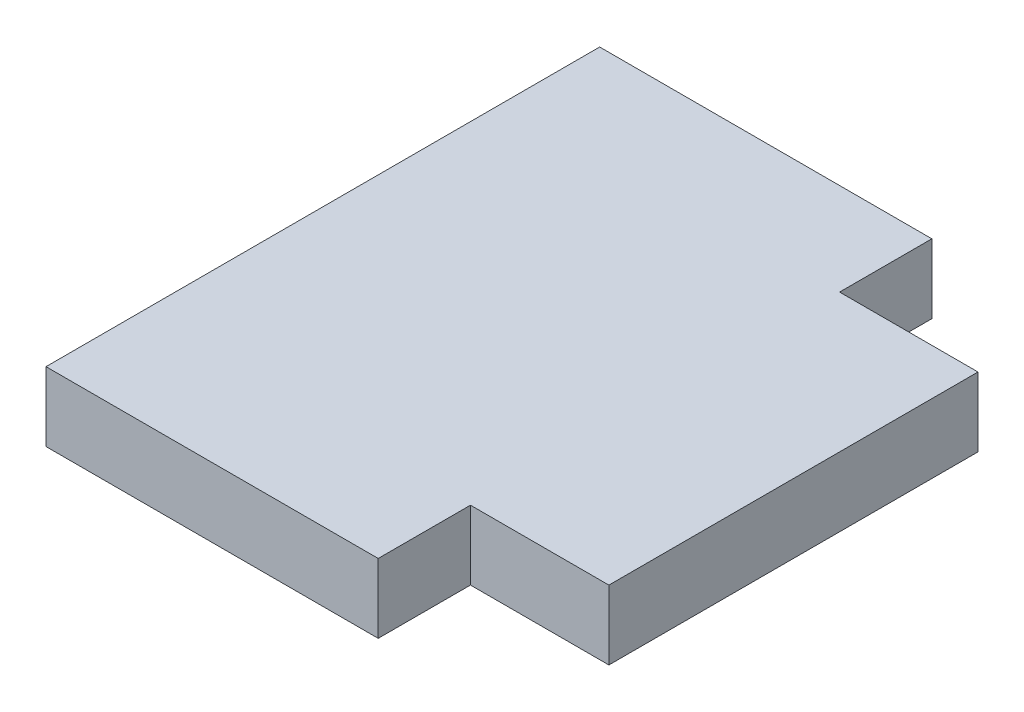
from build123d import *

# Parameters (mm, degrees)
SKETCH_1_W          = 10.2
SKETCH_1_H          = 12
EXTRUDE_1_DEPTH     = 1.5
SKETCH_2_W          = 3
SKETCH_2_H          = 2
CUT_EXTRUDE_1_DEPTH = 2.5


with BuildPart() as part:
    # Эскиз1 → Бобышка-Вытянуть1 (new body)
    with BuildSketch(Plane(origin=(0, 0, 0), x_dir=(1, 0, 0), z_dir=(0, 1, 0))):
        with Locations((5.1, 6)):
            Rectangle(SKETCH_1_W, SKETCH_1_H)
    extrude(amount=EXTRUDE_1_DEPTH)

    # Эскиз2 → Вырез-Вытянуть1 (cut, through all)
    with BuildSketch(Plane(origin=(0, 1.5, 0), x_dir=(1, 0, 0), z_dir=(0, 1, 0))):
        with Locations((8.7, 11)):
            Rectangle(SKETCH_2_W, SKETCH_2_H)
        with Locations((8.7, 1)):
            Rectangle(SKETCH_2_W, SKETCH_2_H)
    extrude(amount=-CUT_EXTRUDE_1_DEPTH, mode=Mode.SUBTRACT)


solid = part.part
